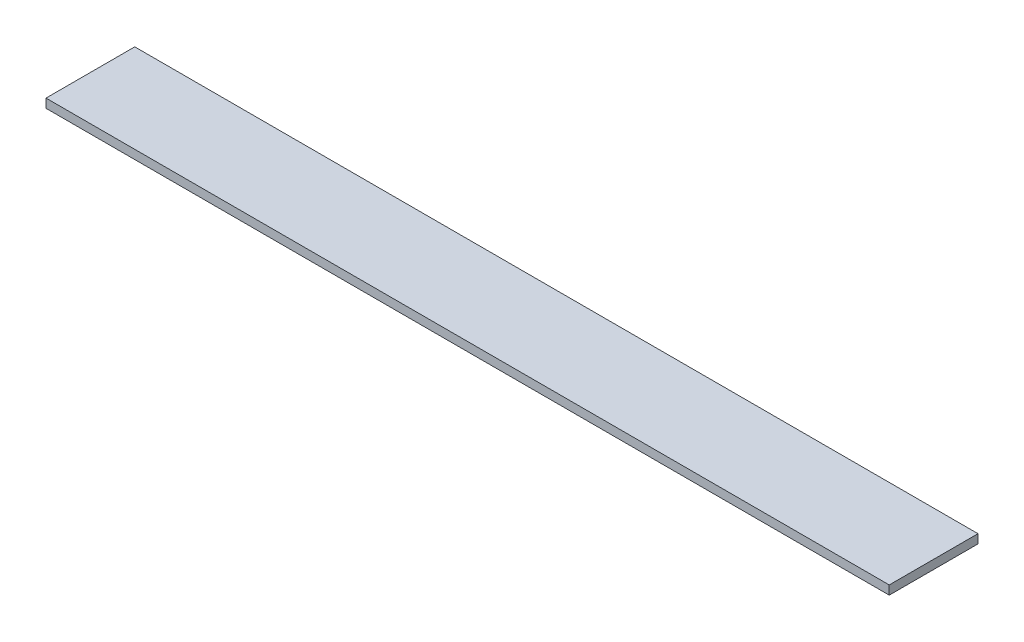
from build123d import *

# Parameters (mm, degrees)
ESQUISSE1_W      = 950
ESQUISSE1_H      = 100
EXTRUSION1_DEPTH = 10


with BuildPart() as part:
    # Esquisse1 → Extrusion1 (new body)
    with BuildSketch(Plane(origin=(0, 0, 0), x_dir=(1, 0, 0), z_dir=(0, 1, 0))):
        with Locations((475, 50)):
            Rectangle(ESQUISSE1_W, ESQUISSE1_H)
    extrude(amount=EXTRUSION1_DEPTH)


solid = part.part
